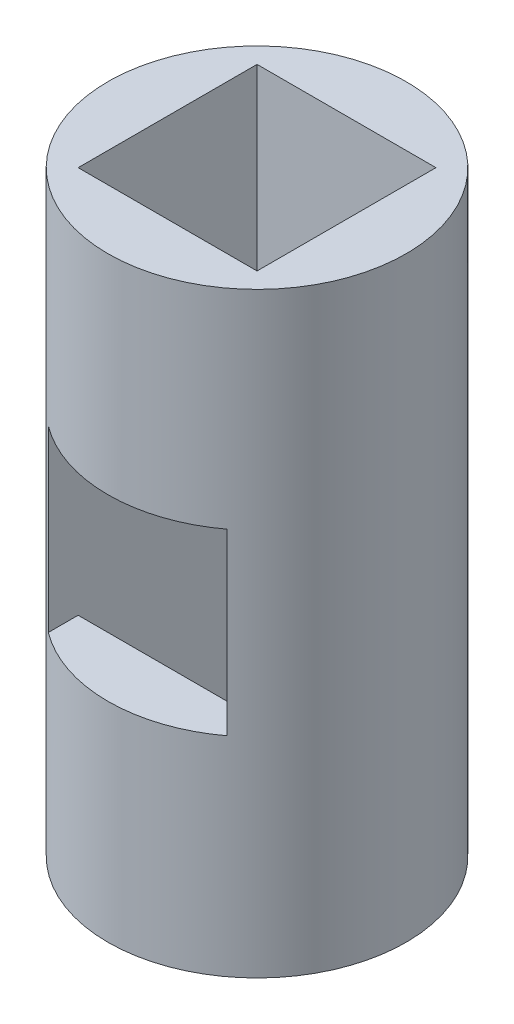
from build123d import *

# Parameters (mm, degrees)
SKETCH1_R               = 25
BOSS_EXTRUDE1_DEPTH     = 100
CUT_EXTRUDE1_DEPTH      = 100
CUT_EXTRUDE2_REACH      = 112.567
CUT_EXTRUDE2_END_RADIUS = 25
SKETCH3_W               = 30
SKETCH3_H               = 30
CUT_EXTRUDE3_REACH      = 112.567
CUT_EXTRUDE3_END_RADIUS = 25
SKETCH4_W               = 30
SKETCH4_H               = 30


with BuildPart() as part:
    # Sketch1 → Boss-Extrude1 (new body)
    with BuildSketch(Plane(origin=(0, 0, 0), x_dir=(1, 0, 0), z_dir=(0, 1, 0))):
        with Locations(Location((0, 0, 0), (0, 0, 270))):
            Circle(SKETCH1_R)
    extrude(amount=BOSS_EXTRUDE1_DEPTH)

    # 3DSketch4 → Cut-Extrude1 (cut)
    with BuildSketch(Plane(origin=(-15, 0, -15), x_dir=(0.7071067811865476, 0, 0.7071067811865476), z_dir=(0, 1, 0))):
        Polygon((0, 0), (21.213203436, 21.213203436), (42.426406871, 0), (21.213203436, -21.213203436), align=None)
    extrude(amount=CUT_EXTRUDE1_DEPTH, mode=Mode.SUBTRACT)

    # Cut-Extrude2: up to this cylinder (the profile starts inside it)
    cut_extrude2_end = Plane(origin=(0, 50, 0), z_dir=(0, -1, 0)) * Cylinder(CUT_EXTRUDE2_END_RADIUS, 276.134, mode=Mode.PRIVATE)
    # Sketch3 → Cut-Extrude2 (cut, up to the surface)
    with BuildSketch(Plane.XY.offset(-15), mode=Mode.PRIVATE) as cut_extrude2_sk1:
        with Locations((0, 50)):
            Rectangle(SKETCH3_W, SKETCH3_H)
    cut_extrude2_tool1 = extrude(cut_extrude2_sk1.sketch, amount=-CUT_EXTRUDE2_REACH, mode=Mode.PRIVATE) & cut_extrude2_end
    add(cut_extrude2_tool1.solids().sort_by_distance((0, 50, -15))[0], mode=Mode.SUBTRACT)

    # Cut-Extrude3: up to this cylinder (the profile starts inside it)
    cut_extrude3_end = Plane(origin=(0, 50, 0), z_dir=(0, -1, 0)) * Cylinder(CUT_EXTRUDE3_END_RADIUS, 276.134, mode=Mode.PRIVATE)
    # Sketch4 → Cut-Extrude3 (cut, up to the surface)
    with BuildSketch(Plane(origin=(0, 0, 15), x_dir=(-1, 0, 0), z_dir=(0, 0, -1)), mode=Mode.PRIVATE) as cut_extrude3_sk1:
        with Locations((0, 50)):
            Rectangle(SKETCH4_W, SKETCH4_H)
    cut_extrude3_tool1 = extrude(cut_extrude3_sk1.sketch, amount=-CUT_EXTRUDE3_REACH, mode=Mode.PRIVATE) & cut_extrude3_end
    add(cut_extrude3_tool1.solids().sort_by_distance((0, 50, 15))[0], mode=Mode.SUBTRACT)


solid = part.part
